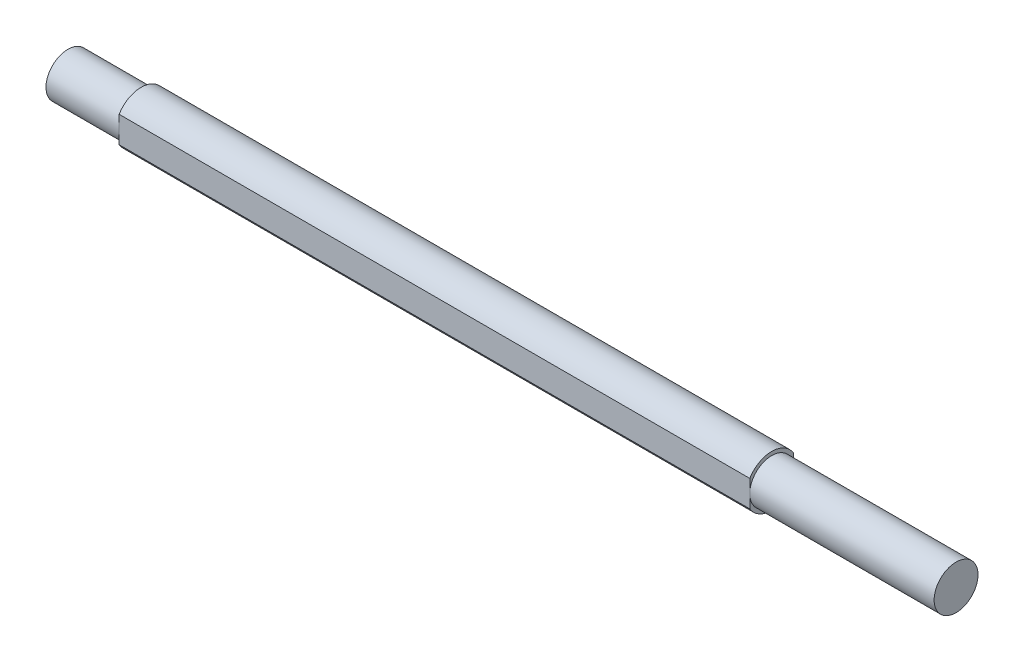
from build123d import *

# Parameters (mm, degrees)
KES_EKSTR_ZYON1_DEPTH = 431
KES_EKSTR_ZYON2_DEPTH = 24


with BuildPart() as part:
    # Çizim1 → Döndür1 (revolve)
    with BuildSketch(Plane.XY):
        Polygon((-303.5, 0), (303.5, 0), (303.5, 15), (177.5, 15), (177.5, 17.5), (-253.5, 17.5), (-253.5, 15), (-303.5, 15), align=None)
    revolve(axis=Axis((-303.5, 0, 0), (1, 0, 0)))

    # Çizim2 → Kes-Ekstrüzyon1 (cut)
    with BuildSketch(Plane.ZY.offset(253.5)):
        with BuildLine():
            Line((-15, 9.013878189), (-15, -9.013878189))
            ThreePointArc((-15, -9.013878189), (-17.5, 0), (-15, 9.013878189))
        make_face()
        with BuildLine():
            Line((15, 9.013878189), (15, -9.013878189))
            ThreePointArc((15, -9.013878189), (17.5, 0), (15, 9.013878189))
        make_face()
    extrude(amount=-KES_EKSTR_ZYON1_DEPTH, mode=Mode.SUBTRACT)

    # Çizim3 → Kes-Ekstrüzyon2 (cut)
    with BuildSketch(Plane(origin=(0, 0, 0), x_dir=(1, 0, 0), z_dir=(0, 1, 0))):
        with BuildLine():
            Line((297.5, -4), (237.5, -4))
            ThreePointArc((237.5, -4), (233.5, 0), (237.5, 4))
            Line((237.5, 4), (297.5, 4))
            ThreePointArc((297.5, 4), (301.5, 0), (297.5, -4))
        make_face()
    extrude(amount=-KES_EKSTR_ZYON2_DEPTH, mode=Mode.SUBTRACT)


solid = part.part
